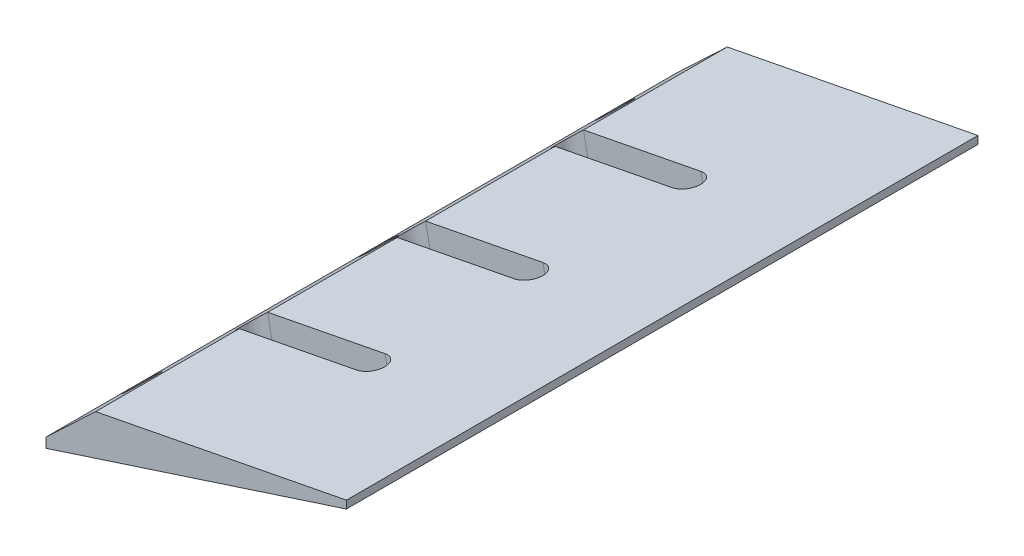
from build123d import *

# Parameters (mm, degrees)
BOSS_EXTRUDE1_DEPTH     = 160
SKETCH3_R               = 1.5
CUT_EXTRUDE1_DEPTH      = 40.389262615
SKETCH4_R               = 4
CUT_EXTRUDE2_DEPTH      = 8
CUT_EXTRUDE3_DEPTH      = 19.147013842
CUT_EXTRUDE3_DEPTH_BACK = 31.333948183
SKETCH6_W               = 4
SKETCH6_H               = 14.600219614
CUT_EXTRUDE4_DEPTH      = 1
CUT_EXTRUDE4_DEPTH_BACK = 161


with BuildPart() as part:
    # Sketch1 → Boss-Extrude1 (new body)
    with BuildSketch(Plane.XY):
        Polygon((0, 0), (-78.530174676, -15.26471963), (-95.10565163, -30.901699437), align=None)
    extrude(amount=BOSS_EXTRUDE1_DEPTH)

    # Sketch3 → Cut-Extrude1 (cut, through all)
    with BuildSketch(Plane(origin=(-3.090169944, 9.510565163, 0), x_dir=(0.951056516, 0.309016994, 0), z_dir=(-0.309016994, 0.951056516, 0))):
        with Locations((-89.701846066, -20)):
            Circle(SKETCH3_R)
        with Locations((-89.701846066, -80)):
            Circle(SKETCH3_R)
        with Locations((-89.701846066, -140)):
            Circle(SKETCH3_R)
    extrude(amount=-CUT_EXTRUDE1_DEPTH, mode=Mode.SUBTRACT)

    # Sketch4 → Cut-Extrude2 (cut)
    with BuildSketch(Plane(origin=(-3.090169944, 9.510565163, 0), x_dir=(0.951056516, 0.309016994, 0), z_dir=(-0.309016994, 0.951056516, 0))):
        with Locations((-89.701846066, -20)):
            Circle(SKETCH4_R)
        with Locations((-89.701846066, -80)):
            Circle(SKETCH4_R)
        with Locations((-89.701846066, -140)):
            Circle(SKETCH4_R)
    extrude(amount=-CUT_EXTRUDE2_DEPTH, mode=Mode.SUBTRACT)

    # Sketch5 → Cut-Extrude3 (cut, two sides)
    with BuildSketch(Plane(origin=(-0.600388906, -0.116703781, 0), x_dir=(0.981627183, 0.190808995, 0), z_dir=(-0.190808995, 0.981627183, 0))) as cut_extrude3_sk:
        with BuildLine():
            Line((-49.109208006, -123.6), (-79.388373798, -123.6))
            ThreePointArc((-79.388373798, -123.6), (-82.988373798, -120), (-79.388373798, -116.4))
            Line((-79.388373798, -116.4), (-49.109208006, -116.4))
            ThreePointArc((-49.109208006, -116.4), (-45.509208006, -120), (-49.109208006, -123.6))
        make_face()
        with BuildLine():
            Line((-49.109208006, -83.6), (-79.388373798, -83.6))
            ThreePointArc((-79.388373798, -83.6), (-82.988373798, -80), (-79.388373798, -76.4))
            Line((-79.388373798, -76.4), (-49.109208006, -76.4))
            ThreePointArc((-49.109208006, -76.4), (-45.509208006, -80), (-49.109208006, -83.6))
        make_face()
        with BuildLine():
            Line((-49.109208006, -43.6), (-79.388373798, -43.6))
            ThreePointArc((-79.388373798, -43.6), (-82.988373798, -40), (-79.388373798, -36.4))
            Line((-79.388373798, -36.4), (-49.109208006, -36.4))
            ThreePointArc((-49.109208006, -36.4), (-45.509208006, -40), (-49.109208006, -43.6))
        make_face()
    extrude(amount=CUT_EXTRUDE3_DEPTH, mode=Mode.SUBTRACT)
    extrude(cut_extrude3_sk.sketch, amount=-CUT_EXTRUDE3_DEPTH_BACK, mode=Mode.SUBTRACT)

    # Sketch6 → Cut-Extrude4 (cut, two sides)
    with BuildSketch(Plane.XY.offset(160)) as cut_extrude4_sk:
        Polygon((-15, 4.492478665), (-15, -6.969839796), (0, -6.969839796), (0, 6.969839796), align=None)
        with Locations((-93.10565163, -29.084878329)):
            Rectangle(SKETCH6_W, SKETCH6_H)
    extrude(amount=CUT_EXTRUDE4_DEPTH, mode=Mode.SUBTRACT)
    extrude(cut_extrude4_sk.sketch, amount=-CUT_EXTRUDE4_DEPTH_BACK, mode=Mode.SUBTRACT)


solid = part.part
